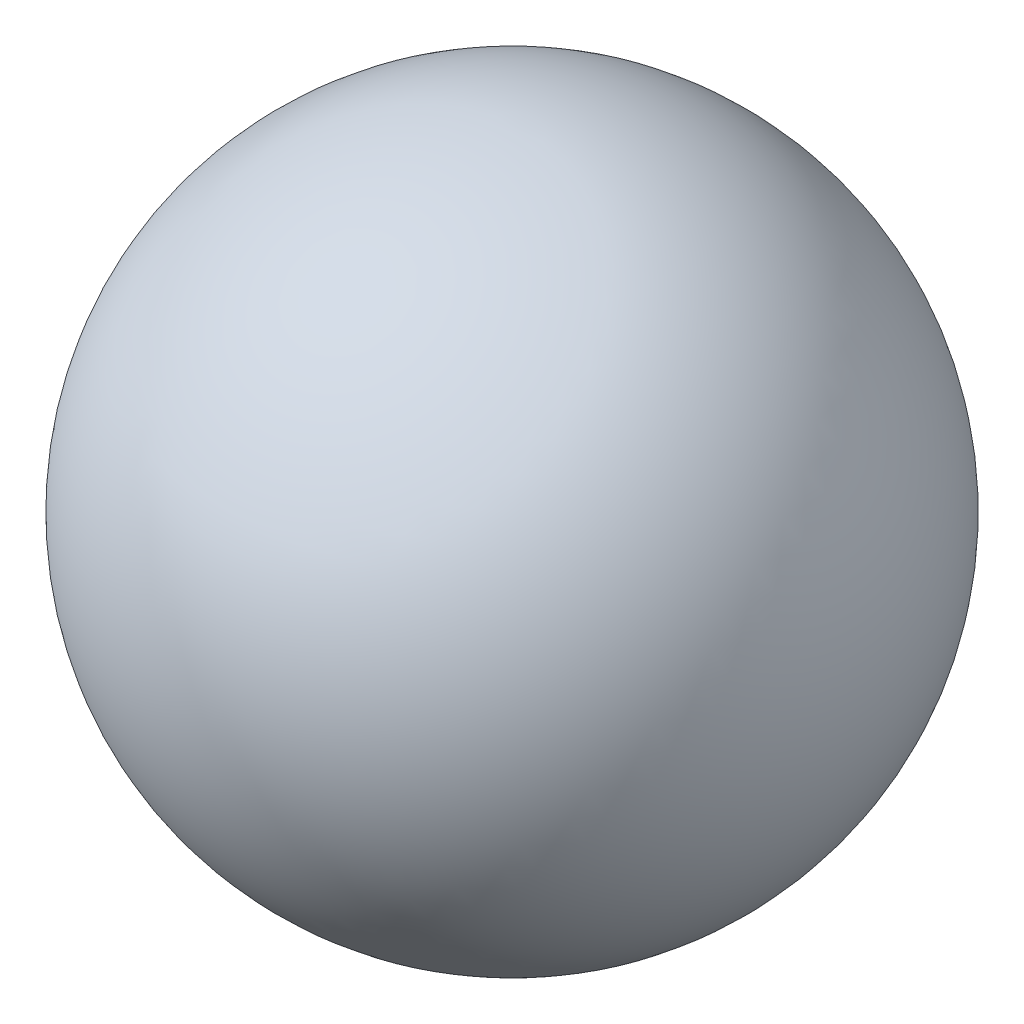
from build123d import *


with BuildPart() as part:
    # Esquisse1 → Révolution1 (revolve)
    with BuildSketch(Plane.XY):
        with BuildLine():
            Line((0, 6.25), (0, -6.25))
            ThreePointArc((0, -6.25), (-6.25, 0), (0, 6.25))
        make_face()
    revolve(axis=Axis((0, 23.295679876, 0), (0, -1, 0)))


solid = part.part
